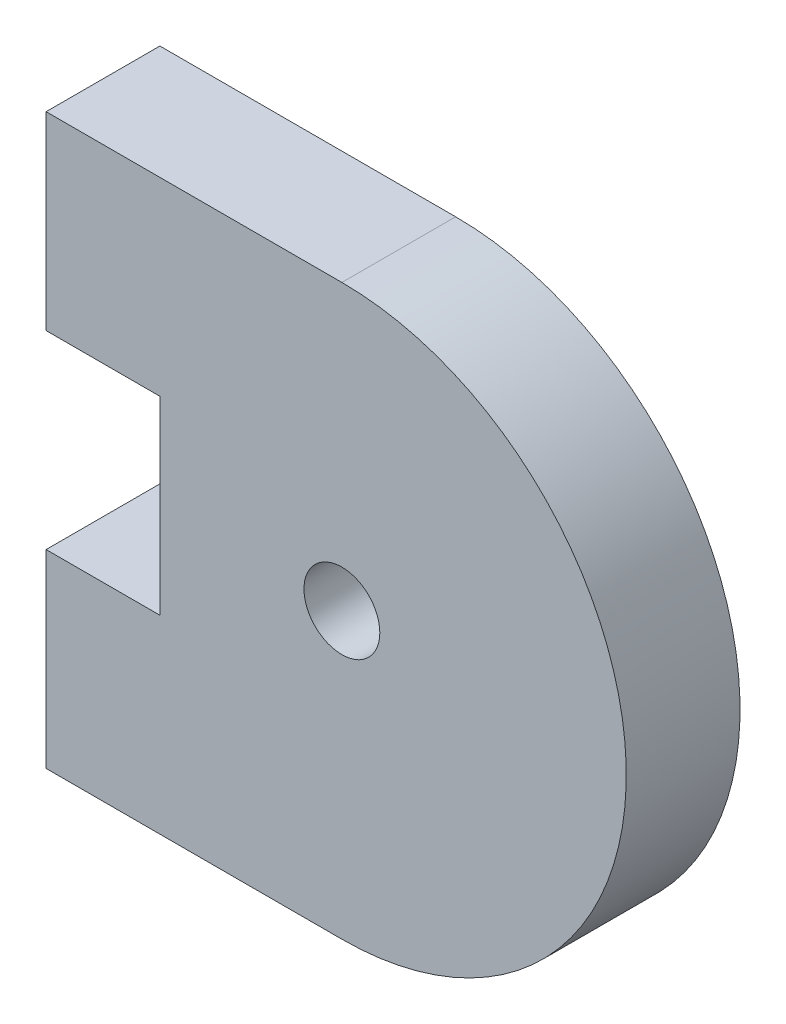
from build123d import *

# Parameters (mm, degrees)
CORTE_EXTERIOR_R        = 1
SALIENTE_EXTRUIR1_DEPTH = 3


with BuildPart() as part:
    # Corte exterior → Saliente-Extruir1 (new body)
    with BuildSketch(Plane.XY):
        with BuildLine():
            Line((42.4, 49.878566683), (34.6, 49.878566683))
            Line((34.6, 49.878566683), (34.6, 44.878566683))
            Line((34.6, 44.878566683), (37.6, 44.878566683))
            Line((37.6, 44.878566683), (37.6, 39.878566683))
            Line((37.6, 39.878566683), (34.6, 39.878566683))
            Line((34.6, 39.878566683), (34.6, 34.878566683))
            Line((34.6, 34.878566683), (42.4, 34.878566683))
            ThreePointArc((42.4, 34.878566683), (49.9, 42.378566683), (42.4, 49.878566683))
        make_face()
        with Locations((42.4, 42.378566683)):
            Circle(CORTE_EXTERIOR_R, mode=Mode.SUBTRACT)
    extrude(amount=SALIENTE_EXTRUIR1_DEPTH)


solid = part.part
